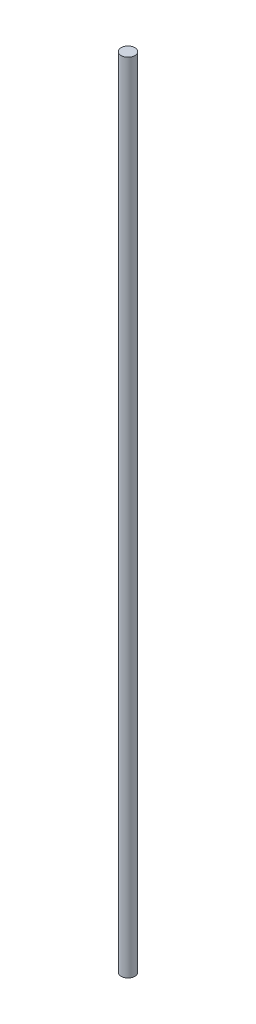
from build123d import *

# Parameters (mm, degrees)
SKETCH1_R           = 3
BOSS_EXTRUDE1_DEPTH = 347.2


with BuildPart() as part:
    # Sketch1 → Boss-Extrude1 (new body)
    with BuildSketch(Plane(origin=(0, 0, 0), x_dir=(1, 0, 0), z_dir=(0, 1, 0))):
        Circle(SKETCH1_R)
    extrude(amount=BOSS_EXTRUDE1_DEPTH)


solid = part.part
